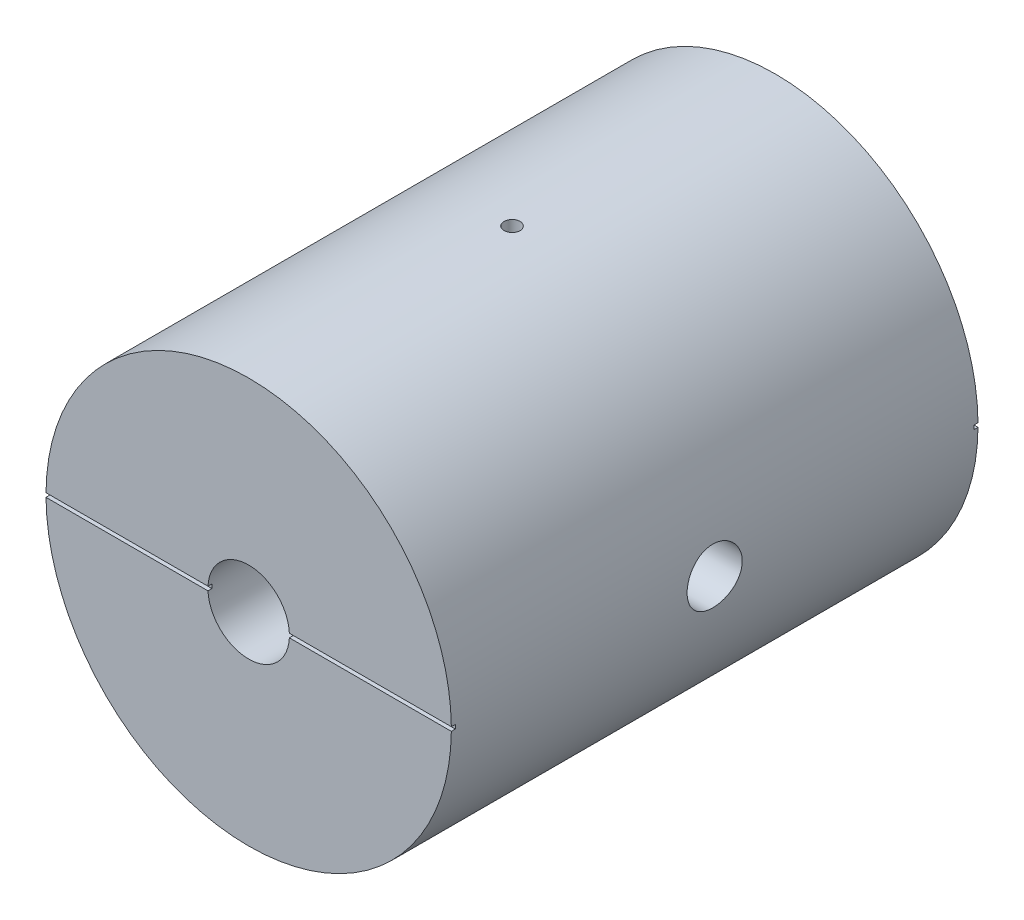
from build123d import *

# Parameters (mm, degrees)
SKETCH1_R                 = 12.7
BASE_EXTRUDE_DEPTH        = 16.5
SKETCH4_R                 = 1.1303
CUT_EXTRUDE1_DEPTH        = 38.570999454
F_8_32_TAPPED_HOLE1_D     = 3.4544
F_8_32_TAPPED_HOLE1_DEPTH = 6.35
F_8_32_TAPPED_HOLE1_TIP   = 1.037806461
CUT_EXTRUDE2_REACH        = 34.844
CUT_EXTRUDE2_END_RADIUS   = 1.1303
SKETCH9_R                 = 1.1303
SKETCH10_W                = 27.33350128
SKETCH10_H                = 0.25
CUT_EXTRUDE3_DEPTH        = 0.25
SKETCH11_R                = 0.5
CUT_EXTRUDE4_DEPTH        = 25.389137098


with BuildPart() as part:
    # Sketch1 → Base-Extrude (new, symmetric)
    with BuildSketch(Plane.XY):
        Circle(SKETCH1_R)
    extrude(amount=BASE_EXTRUDE_DEPTH, both=True)

    # Sketch2 → 1/4-20 Tapped Hole1 (revolve, cut)
    with BuildSketch(Plane(origin=(0, 0, 16.5), x_dir=(0, -1, 0), z_dir=(1, 0, 0))):
        Polygon((0, 0), (0, 7.883816902), (2.5527, 6.35), (2.5527, 0), align=None)
    f_1_4_20_tapped_hole1 = revolve(axis=Axis((0, 0, 22.85), (0, 0, -1)), mode=Mode.SUBTRACT)

    # Mirror1: 1/4-20 Tapped Hole1 across plane
    add(f_1_4_20_tapped_hole1.mirror(Plane.XY), mode=Mode.SUBTRACT)

    # Sketch4 → Cut-Extrude1 (cut, through all)
    with BuildSketch(Plane.XY.offset(16.5)):
        Circle(SKETCH4_R)
    extrude(amount=-CUT_EXTRUDE1_DEPTH, mode=Mode.SUBTRACT)

    # #8-32 Tapped Hole1
    with Locations(Plane(origin=(12.7, 0, 0), x_dir=(0, 0, -1), z_dir=(1, 0, 0))):
        with Locations((0, 0)):
            Hole(F_8_32_TAPPED_HOLE1_D / 2, depth=F_8_32_TAPPED_HOLE1_DEPTH)
            with Locations((0, 0, -(F_8_32_TAPPED_HOLE1_DEPTH + F_8_32_TAPPED_HOLE1_TIP / 2))):  # 118° drill point
                Cone(0, F_8_32_TAPPED_HOLE1_D / 2, F_8_32_TAPPED_HOLE1_TIP, mode=Mode.SUBTRACT)

    # Cut-Extrude2: up to this cylinder (the profile starts outside it)
    cut_extrude2_end = Plane(origin=(0, 0, 0), z_dir=(0, 0, 1)) * Cylinder(CUT_EXTRUDE2_END_RADIUS, 72.9486, mode=Mode.PRIVATE)
    # Sketch9 → Cut-Extrude2 (cut, up to the surface)
    with BuildSketch(Plane(origin=(12.7, 0, 0), x_dir=(0, 0, -1), z_dir=(1, 0, 0)), mode=Mode.PRIVATE) as cut_extrude2_sk1:
        Circle(SKETCH9_R)
    cut_extrude2_tool1 = extrude(cut_extrude2_sk1.sketch, amount=-CUT_EXTRUDE2_REACH, mode=Mode.PRIVATE) - cut_extrude2_end
    add(cut_extrude2_tool1.solids().sort_by_distance((12.7, 0, 0))[0], mode=Mode.SUBTRACT)

    # Sketch10 → Cut-Extrude3 (cut)
    with BuildSketch(Plane.XY.offset(16.5)):
        with Locations((0.215070468, 0)):
            Rectangle(SKETCH10_W, SKETCH10_H)
    cut_extrude3 = extrude(amount=-CUT_EXTRUDE3_DEPTH, mode=Mode.SUBTRACT)

    # Mirror2: Cut-Extrude3 across plane
    add(cut_extrude3.mirror(Plane.XY), mode=Mode.SUBTRACT)

    # Sketch11 → Cut-Extrude4 (cut, through all)
    with BuildSketch(Plane(origin=(0, 0, 0), x_dir=(1, 0, 0), z_dir=(0, 1, 0))):
        with Locations(Location((0, 0, 0), (0, 0, 90))):
            Circle(SKETCH11_R)
    extrude(amount=CUT_EXTRUDE4_DEPTH, mode=Mode.SUBTRACT)


solid = part.part
